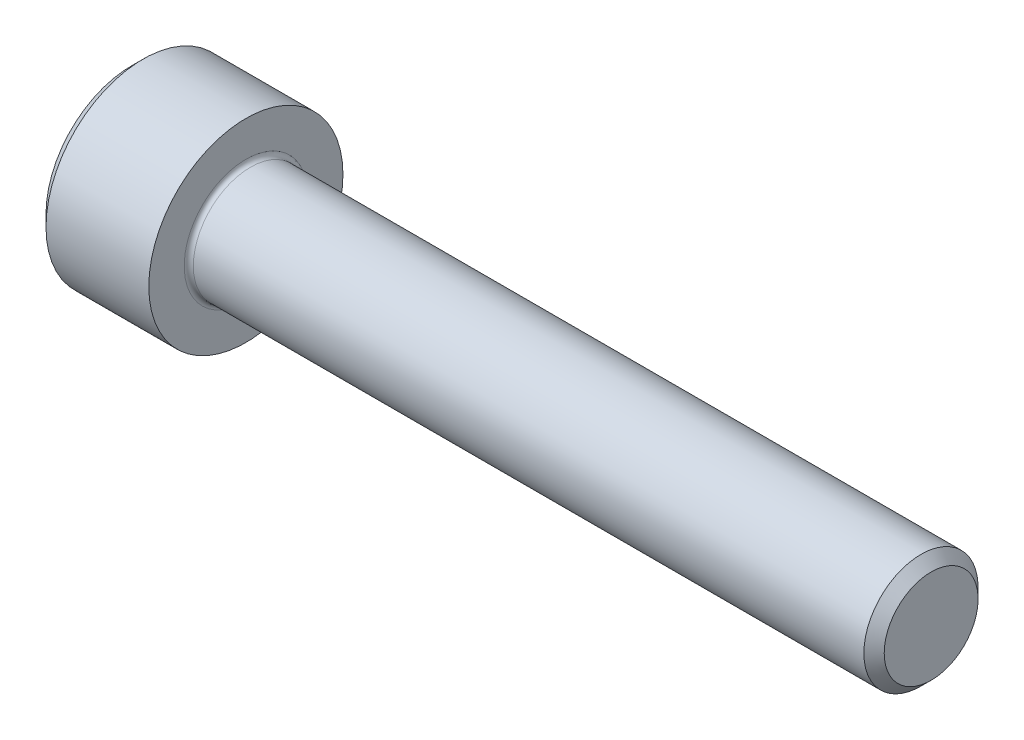
from build123d import *

# Parameters (mm, degrees)
FILLET1_R = 0.2


with BuildPart() as part:
    # BodySke → Base-Revolve (revolve)
    with BuildSketch(Plane.XY):
        Polygon((0, 0), (0, 3.75), (0.5, 4.25), (5, 4.25), (5, 2.5), (34.555, 2.5), (35, 2.055), (35, 0), align=None)
    revolve(axis=Axis((-31.75, 0, 0), (1, 0, 0)))

    # Fillet1
    fillet1_edges = [part.edges().sort_by_distance(p)[0] for p in [
        (5, -2.5, 0),
    ]]
    fillet(fillet1_edges, radius=FILLET1_R)


solid = part.part
